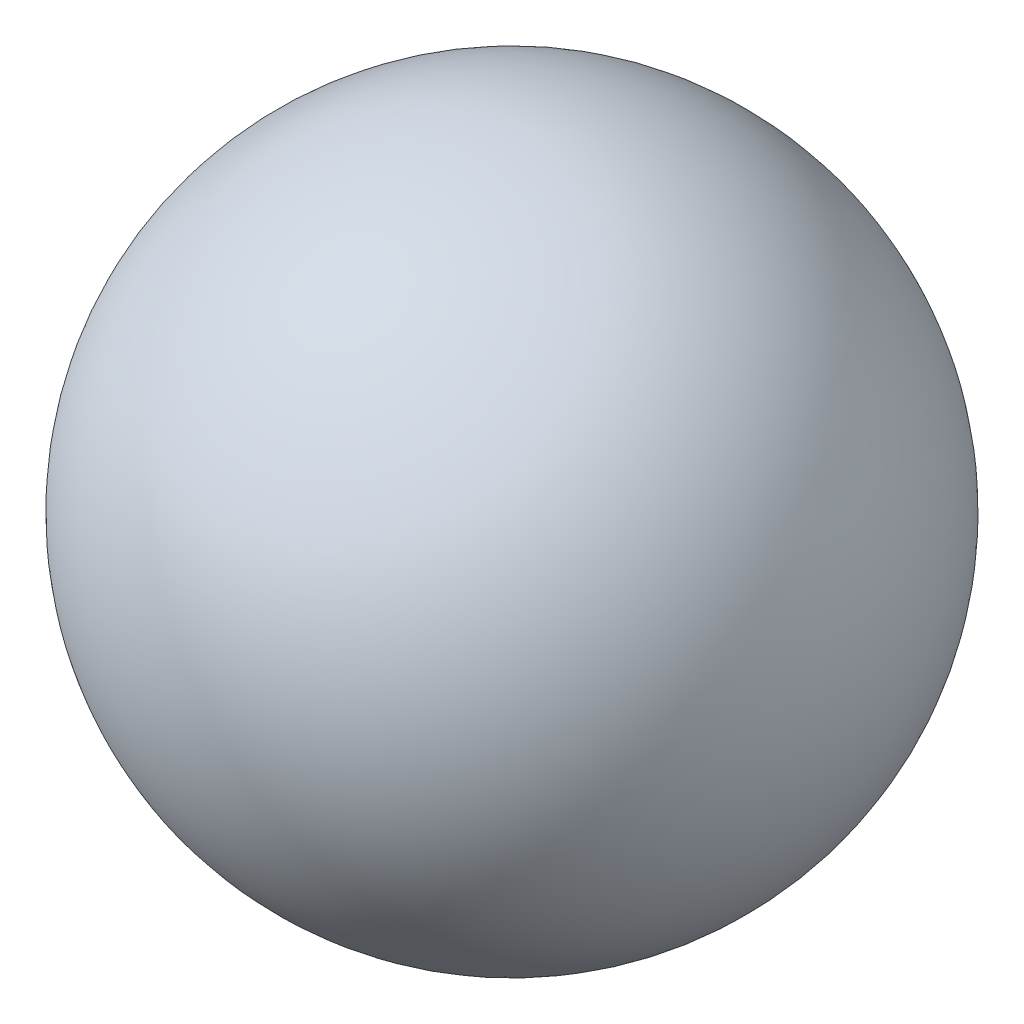
from build123d import *


with BuildPart() as part:
    # Sketch2 → Revolve1 (revolve)
    with BuildSketch(Plane(origin=(0, 0, 0), x_dir=(1, 0, 0), z_dir=(0, 1, 0))):
        with BuildLine():
            Line((-201.335185185, 109.603641233), (-201.335185185, 42.903641233))
            ThreePointArc((-201.335185185, 42.903641233), (-234.685185185, 76.253641233), (-201.335185185, 109.603641233))
        make_face()
    revolve(axis=Axis((-201.335185185, 0, -109.603641233), (0, 0, 1)))


solid = part.part
